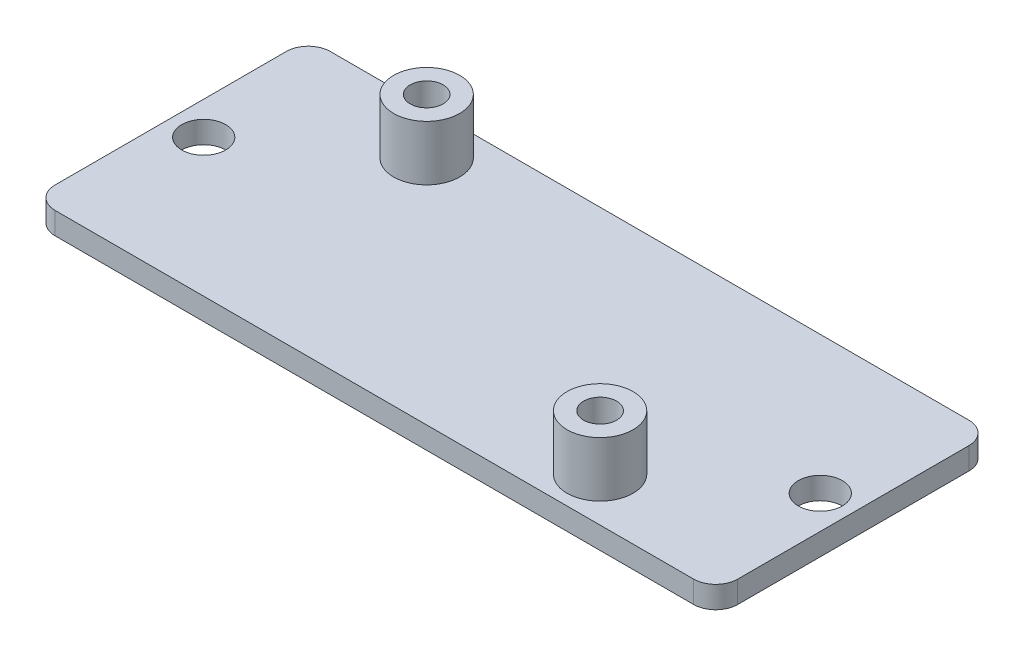
from build123d import *

# Parameters (mm, degrees)
SKETCH_1_W               = 62
SKETCH_1_H               = 25
EXTRUDE_1_DEPTH          = 2
SKETCH_2_R               = 3
EXTRUDE_2_DEPTH          = 5
SKETCH_3_R               = 1.5
CUT_EXTRUDE_1_DEPTH      = 1
CUT_EXTRUDE_1_DEPTH_BACK = 8
SKETCH_4_R               = 2
CUT_EXTRUDE_2_DEPTH      = 6
CUT_EXTRUDE_2_DEPTH_BACK = 3
FILLET_1_R               = 2
FILLET_2_R               = 2
FILLET_3_R               = 2
FILLET_4_R               = 2


with BuildPart() as part:
    # Эскиз1 → Бобышка-Вытянуть1 (new body)
    with BuildSketch(Plane(origin=(0, 0, 0), x_dir=(1, 0, 0), z_dir=(0, 1, 0))):
        with Locations((31, -12.5)):
            Rectangle(SKETCH_1_W, SKETCH_1_H)
    extrude(amount=EXTRUDE_1_DEPTH)

    # Эскиз2 → Бобышка-Вытянуть2 (add)
    with BuildSketch(Plane(origin=(0, 2, 0), x_dir=(1, 0, 0), z_dir=(0, 1, 0))):
        with Locations((14.75, -4)):
            Circle(SKETCH_2_R)
        with Locations((47.5, -21)):
            Circle(SKETCH_2_R)
    extrude(amount=EXTRUDE_2_DEPTH)

    # Эскиз3 → Вырез-Вытянуть1 (cut, two sides)
    with BuildSketch(Plane(origin=(0, 7, 0), x_dir=(1, 0, 0), z_dir=(0, 1, 0))) as cut_extrude_1_sk:
        with Locations((14.75, -4)):
            Circle(SKETCH_3_R)
        with Locations((47.5, -21)):
            Circle(SKETCH_3_R)
    extrude(amount=CUT_EXTRUDE_1_DEPTH, mode=Mode.SUBTRACT)
    extrude(cut_extrude_1_sk.sketch, amount=-CUT_EXTRUDE_1_DEPTH_BACK, mode=Mode.SUBTRACT)

    # Эскиз4 → Вырез-Вытянуть2 (cut, two sides)
    with BuildSketch(Plane(origin=(0, 2, 0), x_dir=(1, 0, 0), z_dir=(0, 1, 0))) as cut_extrude_2_sk:
        with Locations((3, -12.5)):
            Circle(SKETCH_4_R)
        with Locations((59, -12.5)):
            Circle(SKETCH_4_R)
    extrude(amount=CUT_EXTRUDE_2_DEPTH, mode=Mode.SUBTRACT)
    extrude(cut_extrude_2_sk.sketch, amount=-CUT_EXTRUDE_2_DEPTH_BACK, mode=Mode.SUBTRACT)

    # Скругление1
    fillet_1_edges = [part.edges().sort_by_distance(p)[0] for p in [
        (0, 1, 0),
    ]]
    fillet(fillet_1_edges, radius=FILLET_1_R)

    # Скругление2
    fillet_2_edges = [part.edges().sort_by_distance(p)[0] for p in [
        (0, 1, 25),
    ]]
    fillet(fillet_2_edges, radius=FILLET_2_R)

    # Скругление3
    fillet_3_edges = [part.edges().sort_by_distance(p)[0] for p in [
        (62, 1, 25),
    ]]
    fillet(fillet_3_edges, radius=FILLET_3_R)

    # Скругление4
    fillet_4_edges = [part.edges().sort_by_distance(p)[0] for p in [
        (62, 1, 0),
    ]]
    fillet(fillet_4_edges, radius=FILLET_4_R)


solid = part.part
